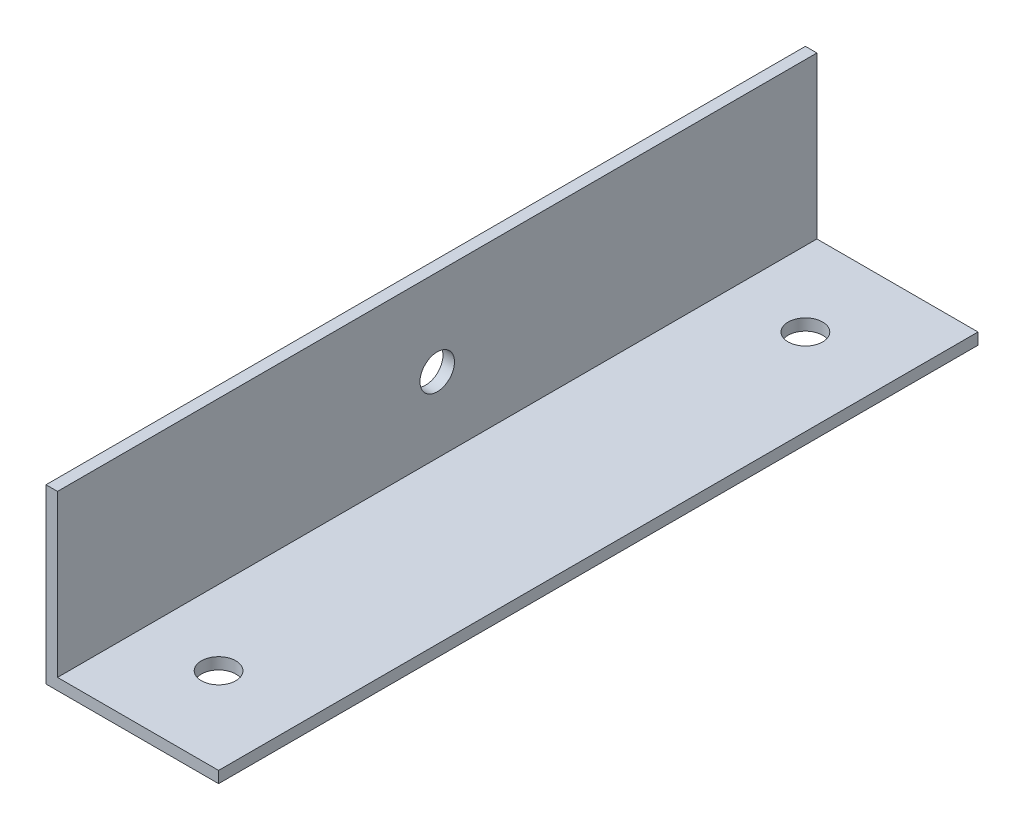
from build123d import *

# Parameters (mm, degrees)
EXTRUDE_1_DEPTH     = 66
SKETCH_3_R          = 1.5
CUT_EXTRUDE_1_DEPTH = 10
SKETCH_4_R          = 1.5
CUT_EXTRUDE_2_DEPTH = 10
SKETCH_5_R          = 1.5
CUT_EXTRUDE_3_DEPTH = 10


with BuildPart() as part:
    # ｽｹｯﾁ1 → ﾎﾞｽ - 押し出し1 (new body)
    with BuildSketch(Plane.XY):
        Polygon((-4.461455774, 6.353305785), (-5.461455774, 6.353305785), (-5.461455774, -8.646694215), (9.538544226, -8.646694215), (9.538544226, -7.646694215), (-4.461455774, -7.646694215), align=None)
    extrude(amount=EXTRUDE_1_DEPTH)

    # ｽｹｯﾁ3 → ｶｯﾄ - 押し出し1 (cut)
    with BuildSketch(Plane(origin=(-4.461455774, 0, 0), x_dir=(0, 0, -1), z_dir=(1, 0, 0))):
        with Locations((-33, -1.146694215)):
            Circle(SKETCH_3_R)
    extrude(amount=-CUT_EXTRUDE_1_DEPTH, mode=Mode.SUBTRACT)

    # ｽｹｯﾁ4 → ｶｯﾄ - 押し出し2 (cut)
    with BuildSketch(Plane(origin=(0, -7.646694215, 0), x_dir=(1, 0, 0), z_dir=(0, 1, 0))):
        with Locations((2.038544226, -7.5)):
            Circle(SKETCH_4_R)
    extrude(amount=-CUT_EXTRUDE_2_DEPTH, mode=Mode.SUBTRACT)

    # ｽｹｯﾁ5 → ｶｯﾄ - 押し出し3 (cut)
    with BuildSketch(Plane(origin=(0, -7.646694215, 0), x_dir=(1, 0, 0), z_dir=(0, 1, 0))):
        with Locations((2.038544226, -58.5)):
            Circle(SKETCH_5_R)
    extrude(amount=-CUT_EXTRUDE_3_DEPTH, mode=Mode.SUBTRACT)


solid = part.part
